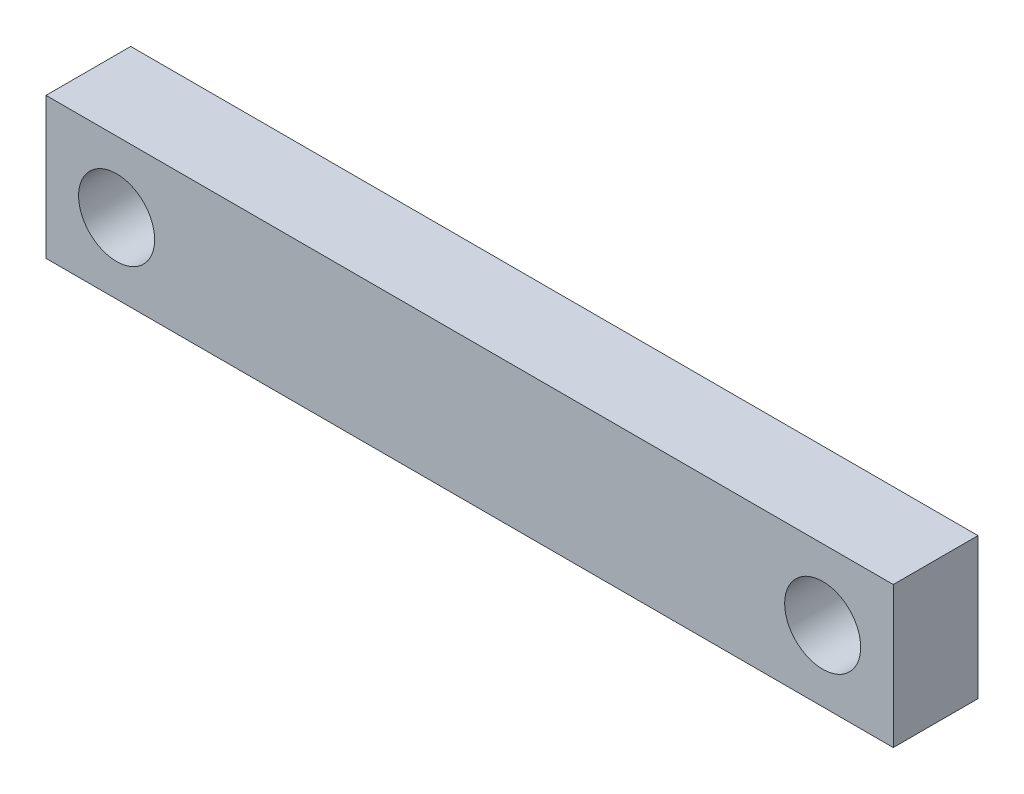
from build123d import *

# Parameters (mm, degrees)
ESQUISSE1_W        = 30
ESQUISSE1_H        = 5
ESQUISSE1_R        = 1.346150104
BOSS_EXTRU_1_DEPTH = 3


with BuildPart() as part:
    # Esquisse1 → Boss.-Extru.1 (new body)
    with BuildSketch(Plane.XY):
        with Locations((15, 2.5)):
            Rectangle(ESQUISSE1_W, ESQUISSE1_H)
        with Locations((2.5, 2.5)):
            Circle(ESQUISSE1_R, mode=Mode.SUBTRACT)
        with Locations((27.5, 2.5)):
            Circle(ESQUISSE1_R, mode=Mode.SUBTRACT)
    extrude(amount=BOSS_EXTRU_1_DEPTH)


solid = part.part
